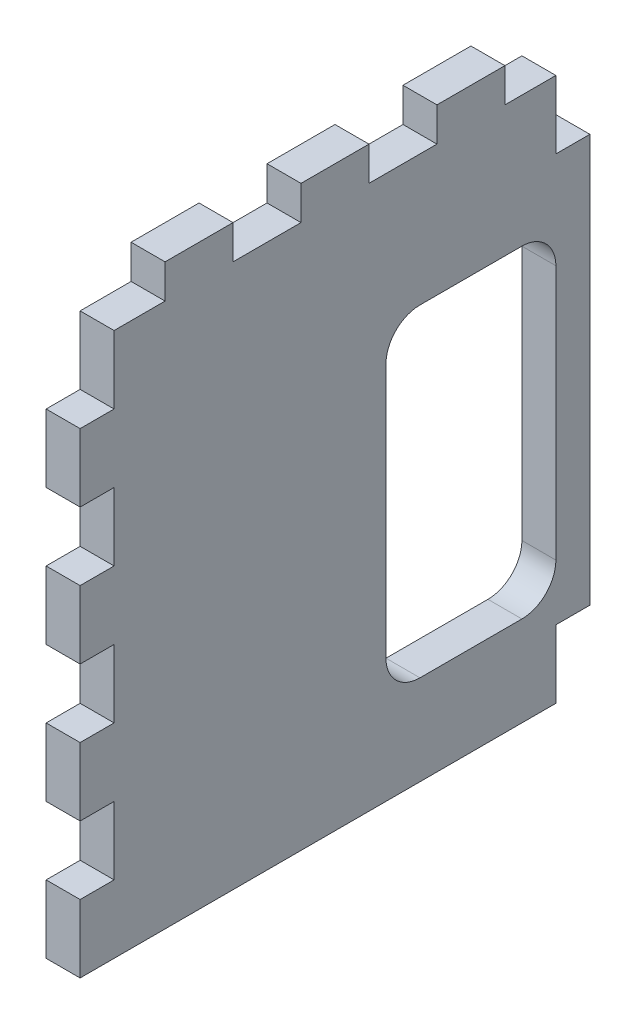
from build123d import *

# Parameters (mm, degrees)
SKETCH1_W           = 95.25
SKETCH1_H           = 107.95
BOSS_EXTRUDE1_DEPTH = 6.35
SKETCH2_W           = 31.75
SKETCH2_H           = 60.325
CUT_EXTRUDE1_DEPTH  = 7.35
SKETCH3_W           = 15.875
SKETCH3_H           = 6.35
SKETCH3_W_2         = 12.7
CUT_EXTRUDE2_DEPTH  = 7.35
SKETCH5_W           = 6.35
SKETCH5_H           = 12.7
CUT_EXTRUDE3_DEPTH  = 7.35
SKETCH6_W           = 6.35
SKETCH6_H           = 12.7
CUT_EXTRUDE4_DEPTH  = 7.35
LPATTERN1_COUNT     = 5
LPATTERN1_PITCH     = 25.4
FILLET1_R           = 6.35


with BuildPart() as part:
    # Sketch1 → Boss-Extrude1 (new body)
    with BuildSketch(Plane(origin=(0, 0, 0), x_dir=(0, 0, -1), z_dir=(1, 0, 0))):
        with Locations((47.625, 53.975)):
            Rectangle(SKETCH1_W, SKETCH1_H)
    extrude(amount=BOSS_EXTRUDE1_DEPTH)

    # Sketch2 → Cut-Extrude1 (cut, through all)
    with BuildSketch(Plane(origin=(6.35, 0, 0), x_dir=(0, 0, -1), z_dir=(1, 0, 0))):
        with Locations((73.025, 46.9875)):
            Rectangle(SKETCH2_W, SKETCH2_H)
    extrude(amount=-CUT_EXTRUDE1_DEPTH, mode=Mode.SUBTRACT)

    # Sketch3 → Cut-Extrude2 (cut, through all)
    with BuildSketch(Plane(origin=(6.35, 0, 0), x_dir=(0, 0, -1), z_dir=(1, 0, 0))):
        with Locations((7.9375, 104.775)):
            Rectangle(SKETCH3_W, SKETCH3_H)
        with Locations((34.925, 104.775)):
            Rectangle(SKETCH3_W_2, SKETCH3_H)
        with Locations((60.325, 104.775)):
            Rectangle(SKETCH3_W_2, SKETCH3_H)
        with Locations((87.3125, 104.775)):
            Rectangle(SKETCH3_W, SKETCH3_H)
    extrude(amount=-CUT_EXTRUDE2_DEPTH, mode=Mode.SUBTRACT)

    # Sketch5 → Cut-Extrude3 (cut, through all)
    with BuildSketch(Plane(origin=(6.35, 0, 0), x_dir=(0, 0, -1), z_dir=(1, 0, 0))):
        with Locations((92.075, 95.25)):
            Rectangle(SKETCH5_W, SKETCH5_H)
        with Locations((92.075, 6.35)):
            Rectangle(SKETCH5_W, SKETCH5_H)
    extrude(amount=-CUT_EXTRUDE3_DEPTH, mode=Mode.SUBTRACT)

    # Sketch6 → Cut-Extrude4 (cut, through all)
    with BuildSketch(Plane(origin=(6.35, 0, 0), x_dir=(0, 0, -1), z_dir=(1, 0, 0))):
        with Locations((3.175, 95.25)):
            Rectangle(SKETCH6_W, SKETCH6_H)
    cut_extrude4 = extrude(amount=-CUT_EXTRUDE4_DEPTH, mode=Mode.SUBTRACT)

    # LPattern1: Cut-Extrude4 ×5
    with Locations(*[(0, -i * LPATTERN1_PITCH, 0) for i in range(1, LPATTERN1_COUNT)]):
        add(cut_extrude4, mode=Mode.SUBTRACT)

    # Fillet1
    fillet1_edges = [part.edges().sort_by_distance(p)[0] for p in [
        (3.175, 16.825, -57.15),
        (3.175, 77.15, -57.15),
        (3.175, 77.15, -88.9),
        (3.175, 16.825, -88.9),
    ]]
    fillet(fillet1_edges, radius=FILLET1_R)


solid = part.part
